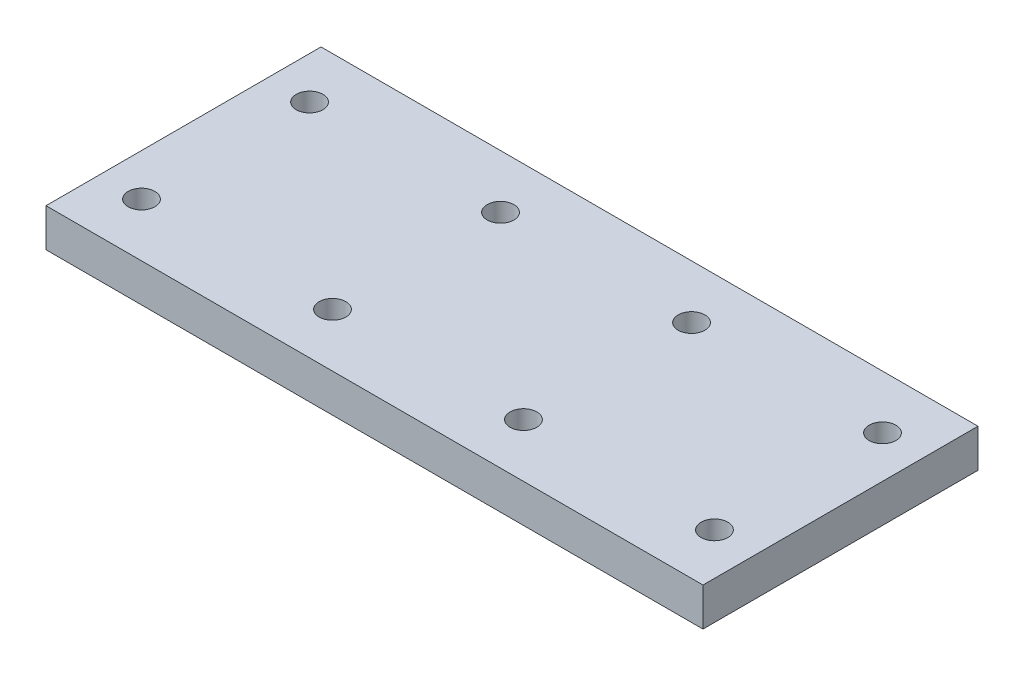
from build123d import *

# Parameters (mm, degrees)
SKETCH_1_W          = 86
SKETCH_1_H          = 36
EXTRUDE_1_DEPTH     = 5
SKETCH_5_R          = 1.75
CUT_EXTRUDE_3_DEPTH = 6


with BuildPart() as part:
    # ｽｹｯﾁ1 → ﾎﾞｽ - 押し出し1 (new body)
    with BuildSketch(Plane(origin=(0, 0, 0), x_dir=(1, 0, 0), z_dir=(0, 1, 0))):
        Rectangle(SKETCH_1_W, SKETCH_1_H)
    extrude(amount=EXTRUDE_1_DEPTH)

    # ｽｹｯﾁ5 → ｶｯﾄ - 押し出し3 (cut, through all)
    with BuildSketch(Plane(origin=(0, 5, 0), x_dir=(1, 0, 0), z_dir=(0, 1, 0))):
        with Locations((37.5, -11)):
            Circle(SKETCH_5_R)
        with Locations((12.5, -11)):
            Circle(SKETCH_5_R)
        with Locations((37.5, 11)):
            Circle(SKETCH_5_R)
        with Locations((12.5, 11)):
            Circle(SKETCH_5_R)
        with Locations((-12.5, 11)):
            Circle(SKETCH_5_R)
        with Locations((-12.5, -11)):
            Circle(SKETCH_5_R)
        with Locations((-37.5, -11)):
            Circle(SKETCH_5_R)
        with Locations((-37.5, 11)):
            Circle(SKETCH_5_R)
    extrude(amount=-CUT_EXTRUDE_3_DEPTH, mode=Mode.SUBTRACT)


solid = part.part
